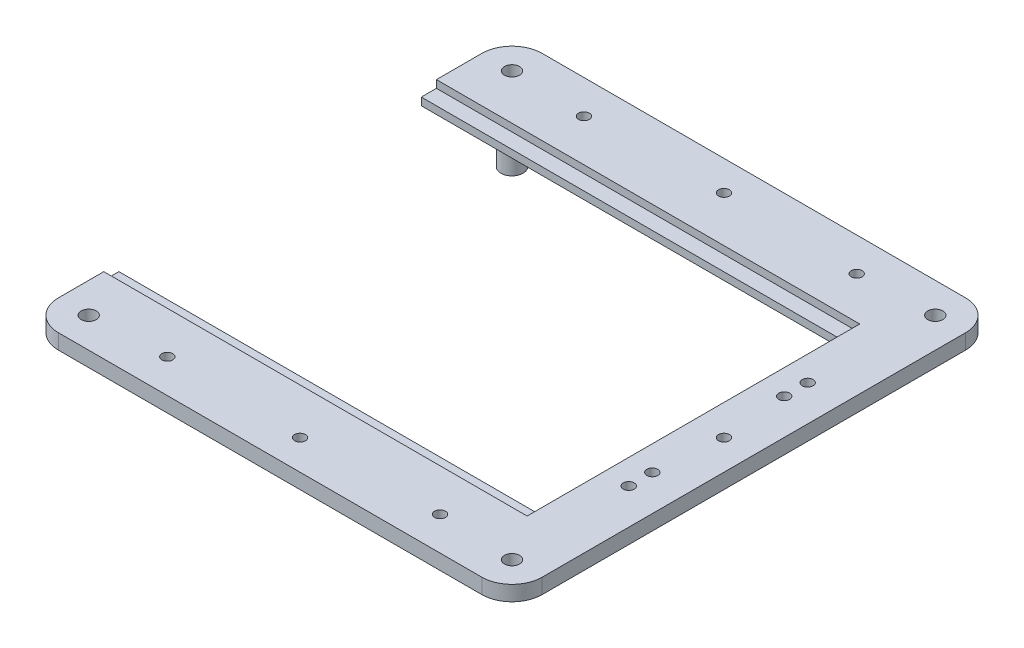
from build123d import *

# Parameters (mm, degrees)
BOSS_EXTRUDE2_DEPTH = 6.35
SKETCH2_R           = 3.175
CUT_EXTRUDE1_DEPTH  = 7.35
SKETCH5_R           = 4.6625
BOSS_EXTRUDE3_DEPTH = 12.7
SKETCH6_W           = 177.8
SKETCH6_H           = 6.35
CUT_EXTRUDE2_DEPTH  = 3.175
SKETCH7_R           = 2.286
CUT_EXTRUDE3_DEPTH  = 12.7
SKETCH8_R           = 2.286
CUT_EXTRUDE4_DEPTH  = 20.05
SKETCH9_R           = 2.286
CUT_EXTRUDE5_DEPTH  = 20.05


with BuildPart() as part:
    # Sketch1 → Boss-Extrude2 (new body)
    with BuildSketch(Plane(origin=(0, 0, 0), x_dir=(1, 0, 0), z_dir=(0, 1, 0))):
        with BuildLine():
            Line((0, 0), (0, 25.4))
            ThreePointArc((0, 25.4), (3.719743879, 34.380256121), (12.7, 38.1))
            Line((12.7, 38.1), (190.5, 38.1))
            ThreePointArc((190.5, 38.1), (199.480256121, 34.380256121), (203.2, 25.4))
            Line((203.2, 25.4), (203.2, -152.4))
            ThreePointArc((203.2, -152.4), (199.480256121, -161.380256121), (190.5, -165.1))
            Line((190.5, -165.1), (12.7, -165.1))
            ThreePointArc((12.7, -165.1), (3.719743879, -161.380256121), (0, -152.4))
            Line((0, -152.4), (0, -127))
            Line((0, -127), (177.8, -127))
            Line((177.8, -127), (177.8, 0))
            Line((177.8, 0), (0, 0))
        make_face()
    extrude(amount=BOSS_EXTRUDE2_DEPTH)

    # Sketch2 → Cut-Extrude1 (cut, through all)
    with BuildSketch(Plane(origin=(0, 6.35, 0), x_dir=(1, 0, 0), z_dir=(0, 1, 0))):
        with Locations((12.7, 25.4)):
            Circle(SKETCH2_R)
        with Locations((190.5, 25.4)):
            Circle(SKETCH2_R)
        with Locations((190.5, -152.4)):
            Circle(SKETCH2_R)
        with Locations((12.7, -152.4)):
            Circle(SKETCH2_R)
    extrude(amount=-CUT_EXTRUDE1_DEPTH, mode=Mode.SUBTRACT)

    # Sketch5 → Boss-Extrude3 (add)
    with BuildSketch(Plane.XZ):
        with Locations((28.575, 136.525)):
            Circle(SKETCH5_R)
        with Locations((174.625, 136.525)):
            Circle(SKETCH5_R)
        with Locations((174.625, -9.525)):
            Circle(SKETCH5_R)
        with Locations((28.575, -9.525)):
            Circle(SKETCH5_R)
    extrude(amount=BOSS_EXTRUDE3_DEPTH)

    # Sketch6 → Cut-Extrude2 (cut)
    with BuildSketch(Plane(origin=(0, 6.35, 0), x_dir=(1, 0, 0), z_dir=(0, 1, 0))):
        with Locations((88.9, -130.175)):
            Rectangle(SKETCH6_W, SKETCH6_H)
        with Locations((88.9, 3.175)):
            Rectangle(SKETCH6_W, SKETCH6_H)
    extrude(amount=-CUT_EXTRUDE2_DEPTH, mode=Mode.SUBTRACT)

    # Sketch7 → Cut-Extrude3 (cut)
    with BuildSketch(Plane(origin=(0, 6.35, 0), x_dir=(1, 0, 0), z_dir=(0, 1, 0))):
        with Locations((188.214, -101.092)):
            Circle(SKETCH7_R)
        with Locations((188.214, -91.186)):
            Circle(SKETCH7_R)
        with Locations((188.214, -35.814)):
            Circle(SKETCH7_R)
        with Locations((188.214, -25.908)):
            Circle(SKETCH7_R)
    extrude(amount=-CUT_EXTRUDE3_DEPTH, mode=Mode.SUBTRACT)

    # Sketch8 → Cut-Extrude4 (cut, through all)
    with BuildSketch(Plane(origin=(0, 6.35, 0), x_dir=(1, 0, 0), z_dir=(0, 1, 0))):
        with Locations((101.6, 25.527)):
            Circle(SKETCH8_R)
        with Locations((190.627, -63.5)):
            Circle(SKETCH8_R)
        with Locations((101.6, -152.527)):
            Circle(SKETCH8_R)
    extrude(amount=-CUT_EXTRUDE4_DEPTH, mode=Mode.SUBTRACT)

    # Sketch9 → Cut-Extrude5 (cut, through all)
    with BuildSketch(Plane(origin=(0, 6.35, 0), x_dir=(1, 0, 0), z_dir=(0, 1, 0))):
        with Locations((44.321, 24)):
            Circle(SKETCH9_R)
        with Locations((44.321, -151)):
            Circle(SKETCH9_R)
        with Locations((158.879, -151)):
            Circle(SKETCH9_R)
        with Locations((158.879, 24)):
            Circle(SKETCH9_R)
    extrude(amount=-CUT_EXTRUDE5_DEPTH, mode=Mode.SUBTRACT)


solid = part.part
